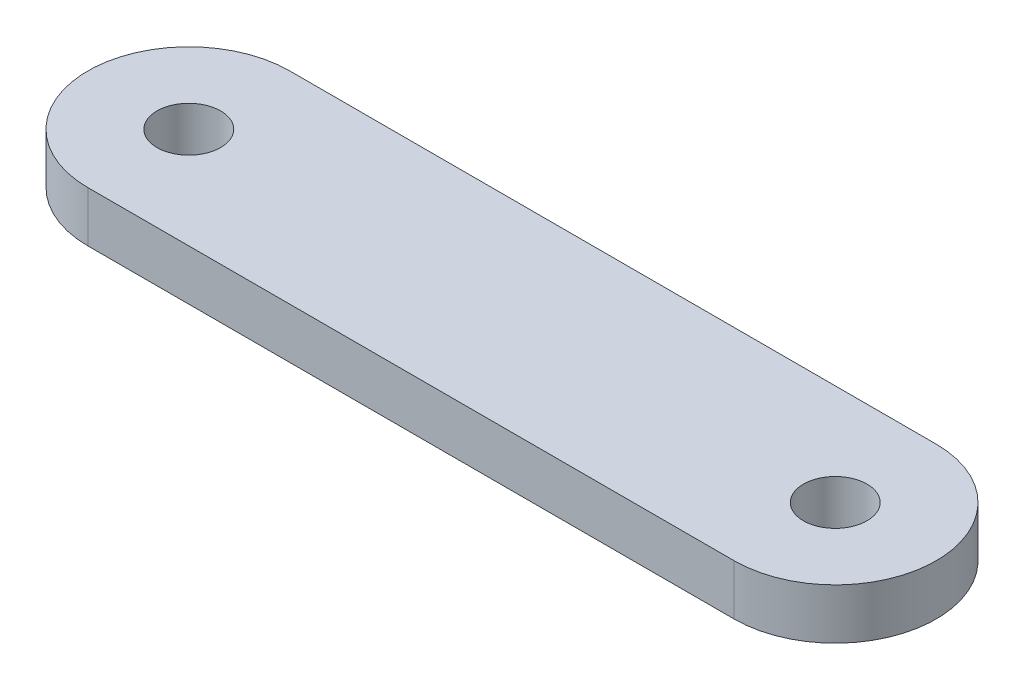
from build123d import *

# Parameters (mm, degrees)
SKETCH1_R           = 2.000000064
BOSS_EXTRUDE1_DEPTH = 3.175


with BuildPart() as part:
    # Sketch1 → Boss-Extrude1 (new body)
    with BuildSketch(Plane(origin=(0, 0, 0), x_dir=(1, 0, 0), z_dir=(0, 1, 0))):
        with BuildLine():
            Line((-20.32, 6.35), (20.32, 6.35))
            ThreePointArc((20.32, 6.35), (26.67, 0), (20.32, -6.35))
            Line((20.32, -6.35), (-20.32, -6.35))
            ThreePointArc((-20.32, -6.35), (-26.67, 0), (-20.32, 6.35))
        make_face()
        with Locations((-20.32, 0)):
            Circle(SKETCH1_R, mode=Mode.SUBTRACT)
        with Locations((20.32, 0)):
            Circle(SKETCH1_R, mode=Mode.SUBTRACT)
    extrude(amount=BOSS_EXTRUDE1_DEPTH)


solid = part.part
